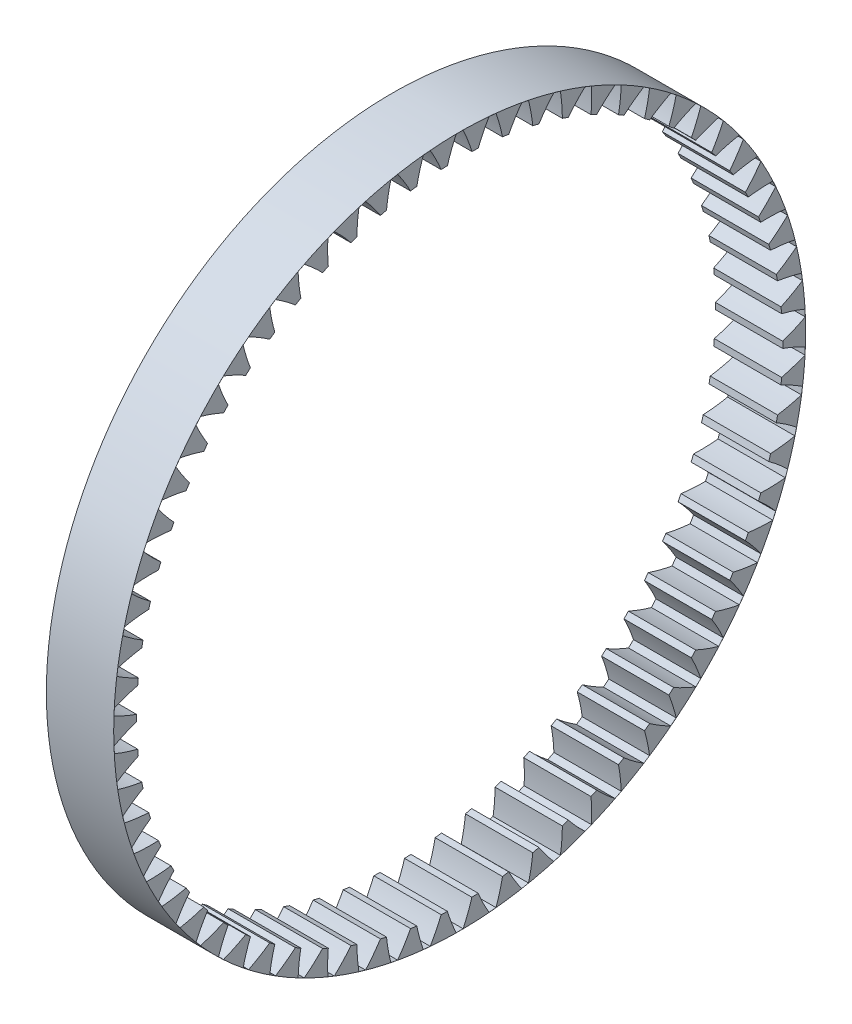
from build123d import *

# Parameters (mm, degrees)
BASPROSKE_W     = 15
BASPROSKE_H     = 5.0889
TOOTHCUT_DEPTH  = 111.047248973
TEETHCUTS_COUNT = 66
TEETHCUTS_ANGLE = 354.545454545


with BuildPart() as part:
    # BasProSke → Base-Revolve (revolve)
    with BuildSketch(Plane(origin=(0, 0, 0), x_dir=(1, 0, 0), z_dir=(0, 1, 0))):
        with Locations((7.5, 74.54445)):
            Rectangle(BASPROSKE_W, BASPROSKE_H)
    revolve(axis=Axis((-10, 0, 0), (1, 0, 0)))

    # TooCutSke → ToothCut (cut, through all)
    with BuildSketch(Plane(origin=(0, 0, 0), x_dir=(0, 0, -1), z_dir=(1, 0, 0))):
        with BuildLine():
            ThreePointArc((2.729357043, 71.922831252), (1.845316604, 74.527539991), (0.770848643, 77.059644592))
            ThreePointArc((0.770848643, 77.059644592), (0, 77.0635), (-0.770848643, 77.059644592))
            ThreePointArc((-0.770848643, 77.059644592), (-1.845316604, 74.527539991), (-2.729357043, 71.922831252))
            ThreePointArc((-2.729357043, 71.922831252), (0, 71.9746), (2.729357043, 71.922831252))
        make_face()
    toothcut = extrude(amount=TOOTHCUT_DEPTH, mode=Mode.SUBTRACT)

    # TeethCuts: ToothCut ×66 about axis
    teethcuts_axis = Axis((-10, 0, 0), (1, 0, 0))
    for i in range(1, TEETHCUTS_COUNT):
        add(toothcut.rotate(teethcuts_axis, i * TEETHCUTS_ANGLE / (TEETHCUTS_COUNT - 1)), mode=Mode.SUBTRACT)


solid = part.part
